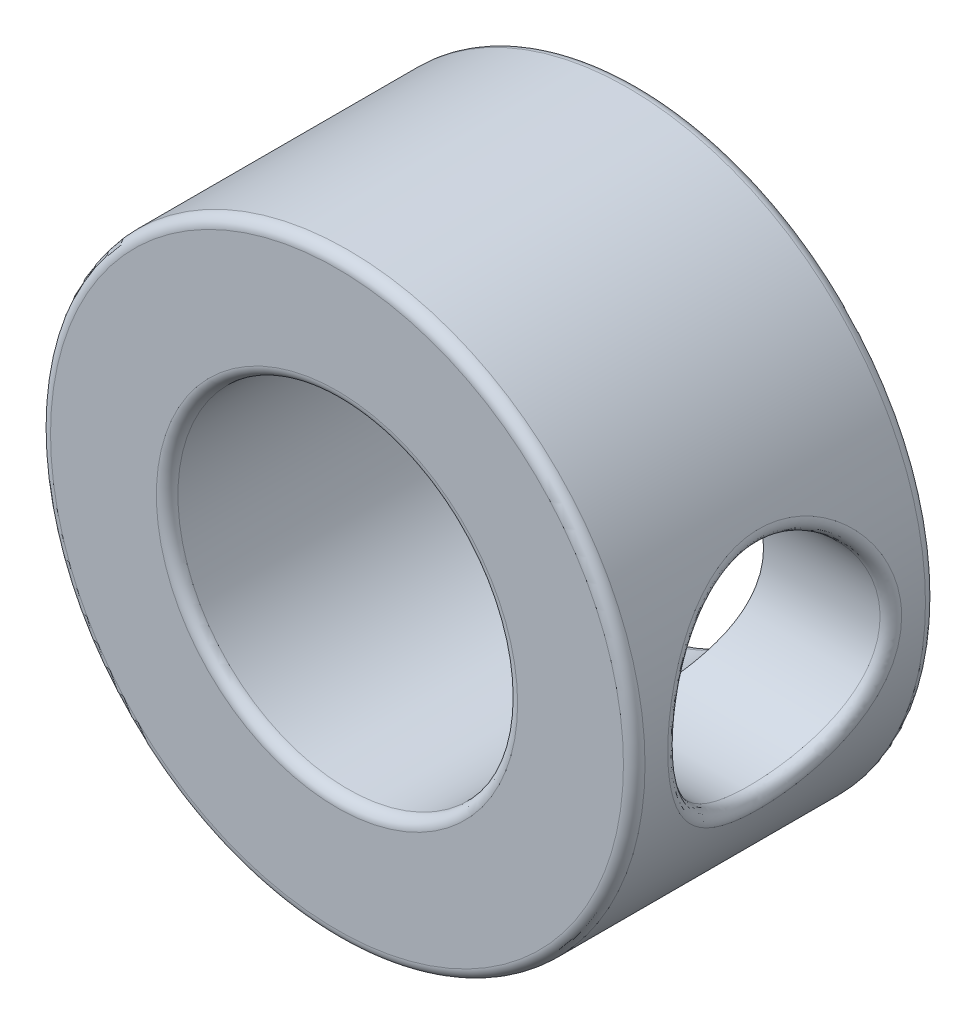
from build123d import *

# Parameters (mm, degrees)
SKETCH2_R           = 7
BOSS_EXTRUDE1_DEPTH = 7.112
SKETCH3_R           = 4
CUT_EXTRUDE1_DEPTH  = 19.05
SKETCH4_R           = 2.5
CUT_EXTRUDE2_DEPTH  = 19.05
FILLET1_R           = 0.254


with BuildPart() as part:
    # Sketch2 → Boss-Extrude1 (new body)
    with BuildSketch(Plane.XY):
        Circle(SKETCH2_R)
    extrude(amount=BOSS_EXTRUDE1_DEPTH)

    # Sketch3 → Cut-Extrude1 (cut)
    with BuildSketch(Plane.XY.offset(7.112)):
        Circle(SKETCH3_R)
    extrude(amount=-CUT_EXTRUDE1_DEPTH, mode=Mode.SUBTRACT)

    # Sketch4 → Cut-Extrude2 (cut)
    with BuildSketch(Plane(origin=(0, 0, 0), x_dir=(0, 0, -1), z_dir=(1, 0, 0))):
        with Locations((-3.5687, 0)):
            Circle(SKETCH4_R)
    extrude(amount=CUT_EXTRUDE2_DEPTH, mode=Mode.SUBTRACT)

    # Fillet1
    fillet1_edges = [part.edges().sort_by_distance(p)[0] for p in [
        (6.538348415, 2.5, 3.5687),
        (-7, 0, 0),
        (-7, 0, 7.112),
        (-4, 0, 0),
        (-4, 0, 7.112),
    ]]
    fillet(fillet1_edges, radius=FILLET1_R)


solid = part.part
